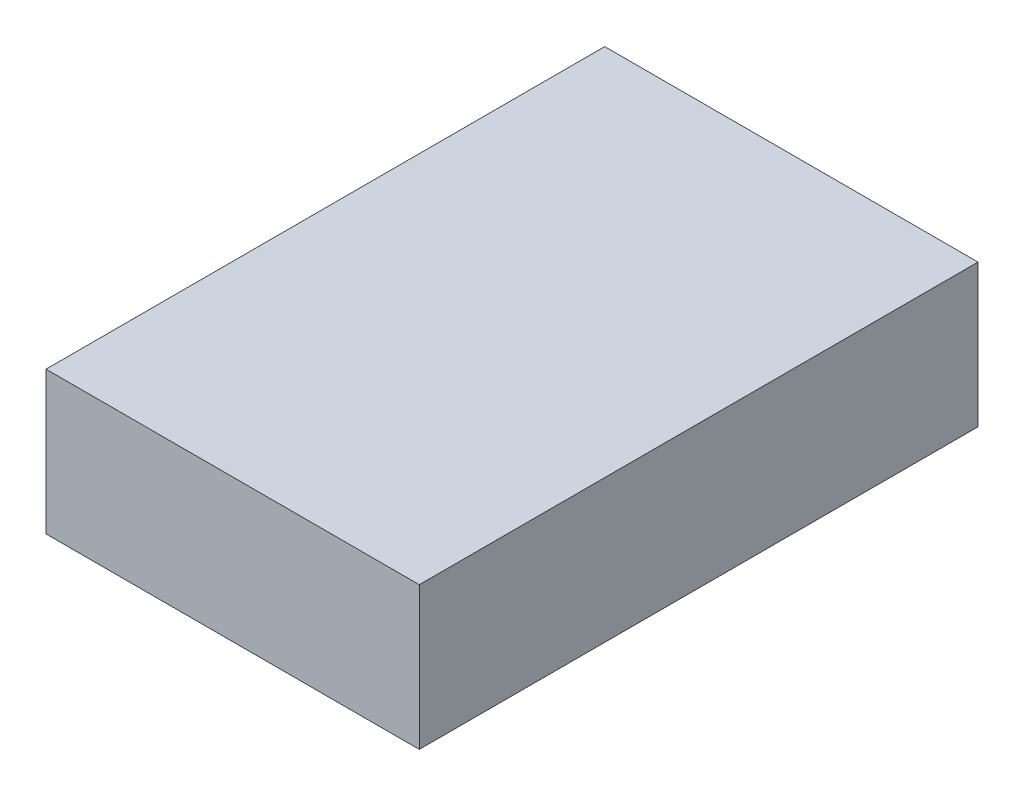
from build123d import *

# Parameters (mm, degrees)
SKETCH1_W           = 39.878
SKETCH1_H           = 59.69
BOSS_EXTRUDE1_DEPTH = 15.24


with BuildPart() as part:
    # Sketch1 → Boss-Extrude1 (new body)
    with BuildSketch(Plane(origin=(0, 0, 0), x_dir=(1, 0, 0), z_dir=(0, 1, 0))):
        Rectangle(SKETCH1_W, SKETCH1_H)
    extrude(amount=BOSS_EXTRUDE1_DEPTH)


solid = part.part
